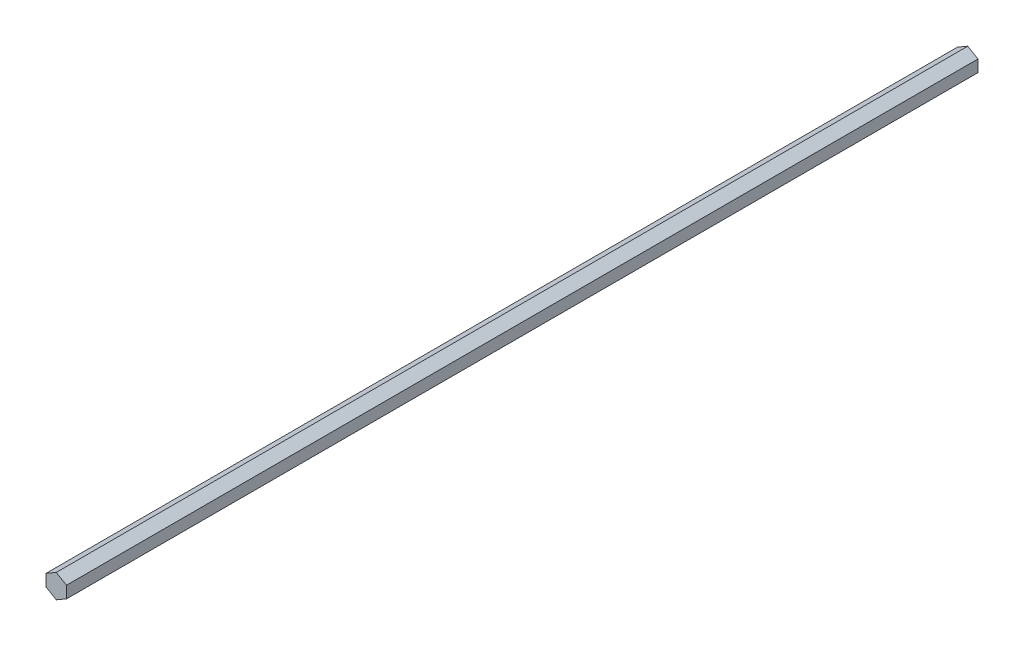
from build123d import *

# Parameters (mm, degrees)
BOSS_EXTRUDE1_DEPTH = 281.94


with BuildPart() as part:
    # Sketch3 → Boss-Extrude1 (new, symmetric)
    with BuildSketch(Plane.XY):
        Polygon((0, 7.332348419), (6.35, 3.666174209), (6.35, -3.666174209), (0, -7.332348419), (-6.35, -3.666174209), (-6.35, 3.666174209), align=None)
    extrude(amount=BOSS_EXTRUDE1_DEPTH, both=True)


solid = part.part
